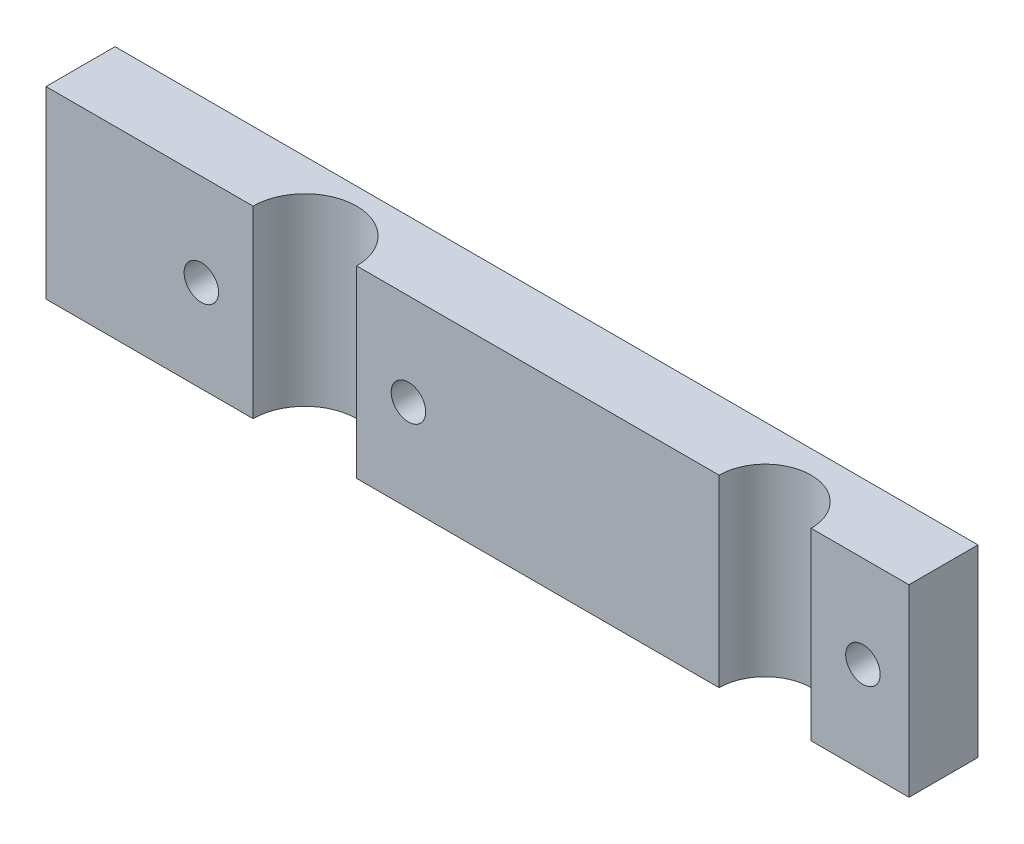
from build123d import *

# Parameters (mm, degrees)
IZIM1_W                     = 150
IZIM1_H                     = 32
Y_KSEKLIK_EKSTR_ZYON1_DEPTH = 12
IZIM2_R                     = 8
IZIM2_R_2                   = 9
KES_EKSTR_ZYON1_DEPTH       = 60
IZIM3_R                     = 3
KES_EKSTR_ZYON2_DEPTH       = 30


with BuildPart() as part:
    # Çizim1 → Yükseklik-Ekstrüzyon1 (new body)
    with BuildSketch(Plane.XY):
        Rectangle(IZIM1_W, IZIM1_H)
    extrude(amount=Y_KSEKLIK_EKSTR_ZYON1_DEPTH)

    # Çizim2 → Kes-Ekstrüzyon1 (cut)
    with BuildSketch(Plane(origin=(0, 16, 0), x_dir=(1, 0, 0), z_dir=(0, 1, 0))):
        with Locations((50, -12)):
            Circle(IZIM2_R)
        with Locations((-30, -12)):
            Circle(IZIM2_R_2)
    extrude(amount=-KES_EKSTR_ZYON1_DEPTH, mode=Mode.SUBTRACT)

    # Çizim3 → Kes-Ekstrüzyon2 (cut)
    with BuildSketch(Plane.XY.offset(12)):
        with Locations((67, 0)):
            Circle(IZIM3_R)
        with Locations((-48, 0)):
            Circle(IZIM3_R)
        with Locations((-12, 0)):
            Circle(IZIM3_R)
    extrude(amount=-KES_EKSTR_ZYON2_DEPTH, mode=Mode.SUBTRACT)


solid = part.part
